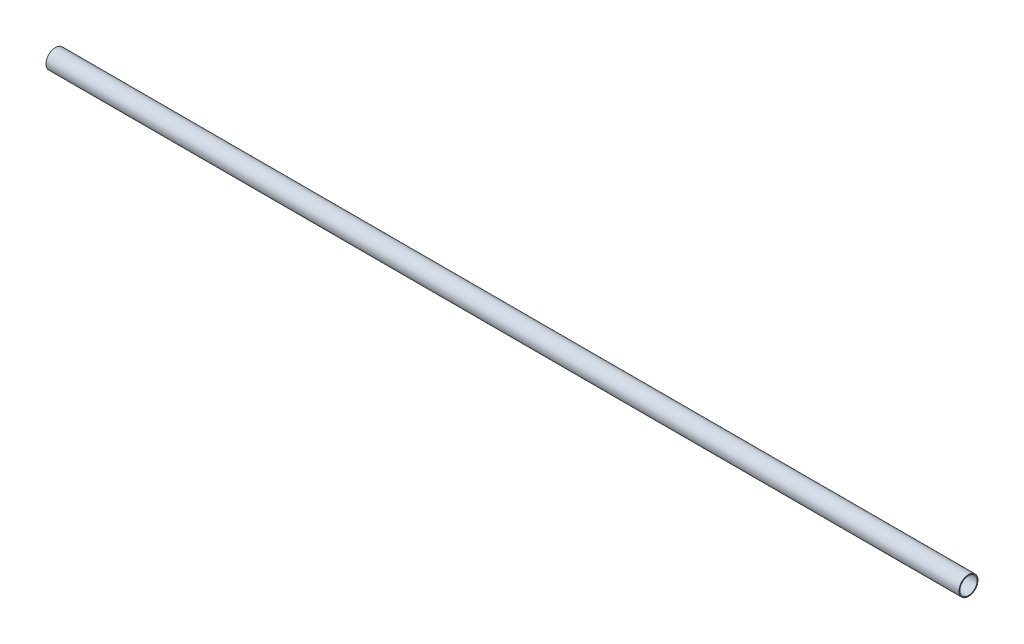
from build123d import *

# Parameters (mm, degrees)
SKETCH4_R           = 9.525
SKETCH4_R_2         = 8.636
BOSS_EXTRUDE1_DEPTH = 457.2


with BuildPart() as part:
    # Sketch4 → Boss-Extrude1 (new body, symmetric)
    with BuildSketch(Plane(origin=(0, 0, 0), x_dir=(0, 0, -1), z_dir=(1, 0, 0))):
        Circle(SKETCH4_R)
        Circle(SKETCH4_R_2, mode=Mode.SUBTRACT)
    extrude(amount=BOSS_EXTRUDE1_DEPTH, both=True)


solid = part.part
